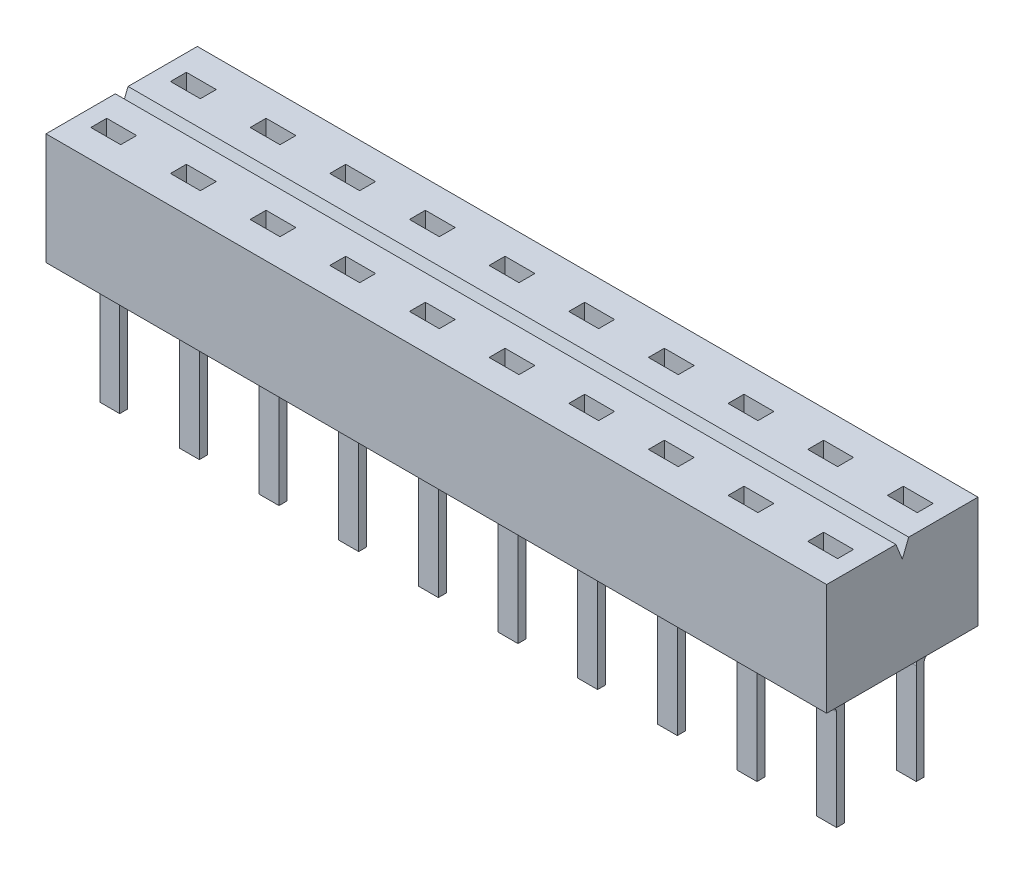
from build123d import *

# Parameters (mm, degrees)
SKETCH1_W            = 24.892
SKETCH1_H            = 4.826
BOSS_EXTRUDE1_DEPTH  = 3.556
BOSS_EXTRUDE2_DEPTH  = 0.635
BOSS_EXTRUDE3_DEPTH  = 0.635
BOSS_EXTRUDE4_DEPTH  = 0.635
BOSS_EXTRUDE5_DEPTH  = 0.635
BOSS_EXTRUDE6_DEPTH  = 0.635
BOSS_EXTRUDE7_DEPTH  = 0.635
BOSS_EXTRUDE8_DEPTH  = 0.635
BOSS_EXTRUDE9_DEPTH  = 0.635
BOSS_EXTRUDE10_DEPTH = 0.635
BOSS_EXTRUDE11_DEPTH = 0.635
BOSS_EXTRUDE12_DEPTH = 0.635
BOSS_EXTRUDE13_DEPTH = 0.635
BOSS_EXTRUDE14_DEPTH = 0.635
BOSS_EXTRUDE15_DEPTH = 0.635
BOSS_EXTRUDE16_DEPTH = 0.635
BOSS_EXTRUDE17_DEPTH = 0.635
BOSS_EXTRUDE18_DEPTH = 0.635
BOSS_EXTRUDE19_DEPTH = 0.635
BOSS_EXTRUDE20_DEPTH = 0.635
BOSS_EXTRUDE21_DEPTH = 0.635
FILLET1_R            = 0.127
FILLET2_R            = 0.381
SKETCH22_W           = 0.9525
SKETCH22_H           = 0.508
CUT_EXTRUDE1_DEPTH   = 3.302
SKETCH23_W           = 0.9525
SKETCH23_H           = 0.508
CUT_EXTRUDE2_DEPTH   = 3.302
SKETCH24_W           = 0.9525
SKETCH24_H           = 0.508
CUT_EXTRUDE3_DEPTH   = 3.302
SKETCH25_W           = 0.9525
SKETCH25_H           = 0.508
CUT_EXTRUDE4_DEPTH   = 3.302
SKETCH26_W           = 0.9525
SKETCH26_H           = 0.508
CUT_EXTRUDE5_DEPTH   = 3.302
SKETCH27_W           = 0.9525
SKETCH27_H           = 0.508
CUT_EXTRUDE6_DEPTH   = 3.302
SKETCH28_W           = 0.9525
SKETCH28_H           = 0.508
CUT_EXTRUDE7_DEPTH   = 3.302
SKETCH29_W           = 0.9525
SKETCH29_H           = 0.508
CUT_EXTRUDE8_DEPTH   = 3.302
SKETCH30_W           = 0.9525
SKETCH30_H           = 0.508
CUT_EXTRUDE9_DEPTH   = 3.302
SKETCH31_W           = 0.9525
SKETCH31_H           = 0.508
CUT_EXTRUDE10_DEPTH  = 3.302
SKETCH32_W           = 0.9525
SKETCH32_H           = 0.508
CUT_EXTRUDE11_DEPTH  = 3.302
SKETCH33_W           = 0.9525
SKETCH33_H           = 0.508
CUT_EXTRUDE12_DEPTH  = 3.302
SKETCH34_W           = 0.9525
SKETCH34_H           = 0.508
CUT_EXTRUDE13_DEPTH  = 3.302
SKETCH35_W           = 0.9525
SKETCH35_H           = 0.508
CUT_EXTRUDE14_DEPTH  = 3.302
SKETCH36_W           = 0.9525
SKETCH36_H           = 0.508
CUT_EXTRUDE15_DEPTH  = 3.302
SKETCH37_W           = 0.9525
SKETCH37_H           = 0.508
CUT_EXTRUDE16_DEPTH  = 3.302
SKETCH38_W           = 0.9525
SKETCH38_H           = 0.508
CUT_EXTRUDE17_DEPTH  = 3.302
SKETCH39_W           = 0.9525
SKETCH39_H           = 0.508
CUT_EXTRUDE18_DEPTH  = 3.302
SKETCH40_W           = 0.9525
SKETCH40_H           = 0.508
CUT_EXTRUDE19_DEPTH  = 3.302
SKETCH41_W           = 0.9525
SKETCH41_H           = 0.508
CUT_EXTRUDE20_DEPTH  = 3.302
CUT_EXTRUDE21_DEPTH  = 25.892


with BuildPart() as part:
    # Sketch1 → Boss-Extrude1 (new body)
    with BuildSketch(Plane.XZ.offset(-0.762)):
        Rectangle(SKETCH1_W, SKETCH1_H)
    extrude(amount=-BOSS_EXTRUDE1_DEPTH)

    # Sketch2 → Boss-Extrude2 (add)
    with BuildSketch(Plane(origin=(8.5725, 0, 0), x_dir=(0, -1, 0), z_dir=(-1, 0, 0))):
        Polygon((0, 1.397), (-0.762, 2.286), (-0.762, 1.895705951), (-0.11682347, 1.143), (3.2512, 1.143), (3.2512, 1.397), align=None)
    extrude(amount=-BOSS_EXTRUDE2_DEPTH)

    # Sketch3 → Boss-Extrude3 (add)
    with BuildSketch(Plane(origin=(6.0325, 0, 0), x_dir=(0, -1, 0), z_dir=(-1, 0, 0))):
        Polygon((0, 1.397), (-0.762, 2.286), (-0.762, 1.895705951), (-0.11682347, 1.143), (3.2512, 1.143), (3.2512, 1.397), align=None)
    extrude(amount=-BOSS_EXTRUDE3_DEPTH)

    # Sketch4 → Boss-Extrude4 (add)
    with BuildSketch(Plane(origin=(3.4925, 0, 0), x_dir=(0, -1, 0), z_dir=(-1, 0, 0))):
        Polygon((0, 1.397), (-0.762, 2.286), (-0.762, 1.895705951), (-0.11682347, 1.143), (3.2512, 1.143), (3.2512, 1.397), align=None)
    extrude(amount=-BOSS_EXTRUDE4_DEPTH)

    # Sketch5 → Boss-Extrude5 (add)
    with BuildSketch(Plane(origin=(0.9525, 0, 0), x_dir=(0, -1, 0), z_dir=(-1, 0, 0))):
        Polygon((0, 1.397), (-0.762, 2.286), (-0.762, 1.895705951), (-0.11682347, 1.143), (3.2512, 1.143), (3.2512, 1.397), align=None)
    extrude(amount=-BOSS_EXTRUDE5_DEPTH)

    # Sketch6 → Boss-Extrude6 (add)
    with BuildSketch(Plane(origin=(-1.5875, 0, 0), x_dir=(0, -1, 0), z_dir=(-1, 0, 0))):
        Polygon((0, 1.397), (-0.762, 2.286), (-0.762, 1.895705951), (-0.11682347, 1.143), (3.2512, 1.143), (3.2512, 1.397), align=None)
    extrude(amount=-BOSS_EXTRUDE6_DEPTH)

    # Sketch7 → Boss-Extrude7 (add)
    with BuildSketch(Plane(origin=(-4.1275, 0, 0), x_dir=(0, -1, 0), z_dir=(-1, 0, 0))):
        Polygon((0, 1.397), (-0.762, 2.286), (-0.762, 1.895705951), (-0.11682347, 1.143), (3.2512, 1.143), (3.2512, 1.397), align=None)
    extrude(amount=-BOSS_EXTRUDE7_DEPTH)

    # Sketch8 → Boss-Extrude8 (add)
    with BuildSketch(Plane(origin=(-6.6675, 0, 0), x_dir=(0, -1, 0), z_dir=(-1, 0, 0))):
        Polygon((0, 1.397), (-0.762, 2.286), (-0.762, 1.895705951), (-0.11682347, 1.143), (3.2512, 1.143), (3.2512, 1.397), align=None)
    extrude(amount=-BOSS_EXTRUDE8_DEPTH)

    # Sketch9 → Boss-Extrude9 (add)
    with BuildSketch(Plane(origin=(-9.2075, 0, 0), x_dir=(0, -1, 0), z_dir=(-1, 0, 0))):
        Polygon((0, 1.397), (-0.762, 2.286), (-0.762, 1.895705951), (-0.11682347, 1.143), (3.2512, 1.143), (3.2512, 1.397), align=None)
    extrude(amount=-BOSS_EXTRUDE9_DEPTH)

    # Sketch10 → Boss-Extrude10 (add)
    with BuildSketch(Plane(origin=(-11.7475, 0, 0), x_dir=(0, -1, 0), z_dir=(-1, 0, 0))):
        Polygon((0, 1.397), (-0.762, 2.286), (-0.762, 1.895705951), (-0.11682347, 1.143), (3.2512, 1.143), (3.2512, 1.397), align=None)
    extrude(amount=-BOSS_EXTRUDE10_DEPTH)

    # Sketch11 → Boss-Extrude11 (add)
    with BuildSketch(Plane(origin=(11.1125, 0, 0), x_dir=(0, -1, 0), z_dir=(-1, 0, 0))):
        Polygon((-0.11682347, -1.143), (-0.762, -1.895705951), (-0.762, -2.286), (0, -1.397), (3.2512, -1.397), (3.2512, -1.143), align=None)
    extrude(amount=-BOSS_EXTRUDE11_DEPTH)

    # Sketch12 → Boss-Extrude12 (add)
    with BuildSketch(Plane(origin=(8.5725, 0, 0), x_dir=(0, -1, 0), z_dir=(-1, 0, 0))):
        Polygon((-0.11682347, -1.143), (-0.762, -1.895705951), (-0.762, -2.286), (0, -1.397), (3.2512, -1.397), (3.2512, -1.143), align=None)
    extrude(amount=-BOSS_EXTRUDE12_DEPTH)

    # Sketch13 → Boss-Extrude13 (add)
    with BuildSketch(Plane(origin=(6.0325, 0, 0), x_dir=(0, -1, 0), z_dir=(-1, 0, 0))):
        Polygon((-0.11682347, -1.143), (-0.762, -1.895705951), (-0.762, -2.286), (0, -1.397), (3.2512, -1.397), (3.2512, -1.143), align=None)
    extrude(amount=-BOSS_EXTRUDE13_DEPTH)

    # Sketch14 → Boss-Extrude14 (add)
    with BuildSketch(Plane(origin=(3.4925, 0, 0), x_dir=(0, -1, 0), z_dir=(-1, 0, 0))):
        Polygon((-0.11682347, -1.143), (-0.762, -1.895705951), (-0.762, -2.286), (0, -1.397), (3.2512, -1.397), (3.2512, -1.143), align=None)
    extrude(amount=-BOSS_EXTRUDE14_DEPTH)

    # Sketch15 → Boss-Extrude15 (add)
    with BuildSketch(Plane(origin=(0.9525, 0, 0), x_dir=(0, -1, 0), z_dir=(-1, 0, 0))):
        Polygon((-0.11682347, -1.143), (-0.762, -1.895705951), (-0.762, -2.286), (0, -1.397), (3.2512, -1.397), (3.2512, -1.143), align=None)
    extrude(amount=-BOSS_EXTRUDE15_DEPTH)

    # Sketch16 → Boss-Extrude16 (add)
    with BuildSketch(Plane(origin=(-1.5875, 0, 0), x_dir=(0, -1, 0), z_dir=(-1, 0, 0))):
        Polygon((-0.11682347, -1.143), (-0.762, -1.895705951), (-0.762, -2.286), (0, -1.397), (3.2512, -1.397), (3.2512, -1.143), align=None)
    extrude(amount=-BOSS_EXTRUDE16_DEPTH)

    # Sketch17 → Boss-Extrude17 (add)
    with BuildSketch(Plane(origin=(-4.1275, 0, 0), x_dir=(0, -1, 0), z_dir=(-1, 0, 0))):
        Polygon((-0.11682347, -1.143), (-0.762, -1.895705951), (-0.762, -2.286), (0, -1.397), (3.2512, -1.397), (3.2512, -1.143), align=None)
    extrude(amount=-BOSS_EXTRUDE17_DEPTH)

    # Sketch18 → Boss-Extrude18 (add)
    with BuildSketch(Plane(origin=(-6.6675, 0, 0), x_dir=(0, -1, 0), z_dir=(-1, 0, 0))):
        Polygon((-0.11682347, -1.143), (-0.762, -1.895705951), (-0.762, -2.286), (0, -1.397), (3.2512, -1.397), (3.2512, -1.143), align=None)
    extrude(amount=-BOSS_EXTRUDE18_DEPTH)

    # Sketch19 → Boss-Extrude19 (add)
    with BuildSketch(Plane(origin=(-9.2075, 0, 0), x_dir=(0, -1, 0), z_dir=(-1, 0, 0))):
        Polygon((-0.11682347, -1.143), (-0.762, -1.895705951), (-0.762, -2.286), (0, -1.397), (3.2512, -1.397), (3.2512, -1.143), align=None)
    extrude(amount=-BOSS_EXTRUDE19_DEPTH)

    # Sketch20 → Boss-Extrude20 (add)
    with BuildSketch(Plane(origin=(-11.7475, 0, 0), x_dir=(0, -1, 0), z_dir=(-1, 0, 0))):
        Polygon((-0.11682347, -1.143), (-0.762, -1.895705951), (-0.762, -2.286), (0, -1.397), (3.2512, -1.397), (3.2512, -1.143), align=None)
    extrude(amount=-BOSS_EXTRUDE20_DEPTH)

    # Sketch21 → Boss-Extrude21 (add)
    with BuildSketch(Plane(origin=(11.1125, 0, 0), x_dir=(0, -1, 0), z_dir=(-1, 0, 0))):
        Polygon((0, 1.397), (-0.762, 2.286), (-0.762, 1.895705951), (-0.11682347, 1.143), (3.2512, 1.143), (3.2512, 1.397), align=None)
    extrude(amount=-BOSS_EXTRUDE21_DEPTH)

    # Fillet1
    fillet1_edges = [part.edges().sort_by_distance(p)[0] for p in [
        (-6.35, 0, 1.397),
        (-8.89, 0, 1.397),
        (-11.43, 0, 1.397),
        (8.89, 0, 1.397),
        (11.43, 0, -1.397),
        (8.89, 0, -1.397),
        (6.35, 0, -1.397),
        (3.81, 0, -1.397),
        (1.27, 0, -1.397),
        (-1.27, 0, -1.397),
        (-3.81, 0, -1.397),
        (-6.35, 0, -1.397),
        (-8.89, 0, -1.397),
        (-11.43, 0, -1.397),
        (6.35, 0, 1.397),
        (11.43, 0, 1.397),
        (3.81, 0, 1.397),
        (1.27, 0, 1.397),
        (-1.27, 0, 1.397),
        (-3.81, 0, 1.397),
    ]]
    fillet(fillet1_edges, radius=FILLET1_R)

    # Fillet2
    fillet2_edges = [part.edges().sort_by_distance(p)[0] for p in [
        (-6.35, 0.11682347, 1.143),
        (-8.89, 0.11682347, 1.143),
        (-11.43, 0.11682347, 1.143),
        (11.43, 0.11682347, -1.143),
        (8.89, 0.11682347, 1.143),
        (8.89, 0.11682347, -1.143),
        (6.35, 0.11682347, -1.143),
        (3.81, 0.11682347, -1.143),
        (1.27, 0.11682347, -1.143),
        (-1.27, 0.11682347, -1.143),
        (-3.81, 0.11682347, -1.143),
        (-6.35, 0.11682347, -1.143),
        (-8.89, 0.11682347, -1.143),
        (-11.43, 0.11682347, -1.143),
        (11.43, 0.11682347, 1.143),
        (6.35, 0.11682347, 1.143),
        (3.81, 0.11682347, 1.143),
        (1.27, 0.11682347, 1.143),
        (-1.27, 0.11682347, 1.143),
        (-3.81, 0.11682347, 1.143),
    ]]
    fillet(fillet2_edges, radius=FILLET2_R)

    # Sketch22 → Cut-Extrude1 (cut)
    with BuildSketch(Plane(origin=(0, 4.318, 0), x_dir=(-1, 0, 0), z_dir=(0, 1, 0))):
        with Locations((11.43, 1.27)):
            Rectangle(SKETCH22_W, SKETCH22_H)
    extrude(amount=-CUT_EXTRUDE1_DEPTH, mode=Mode.SUBTRACT)

    # Sketch23 → Cut-Extrude2 (cut)
    with BuildSketch(Plane(origin=(0, 4.318, 0), x_dir=(-1, 0, 0), z_dir=(0, 1, 0))):
        with Locations((8.89, 1.27)):
            Rectangle(SKETCH23_W, SKETCH23_H)
    extrude(amount=-CUT_EXTRUDE2_DEPTH, mode=Mode.SUBTRACT)

    # Sketch24 → Cut-Extrude3 (cut)
    with BuildSketch(Plane(origin=(0, 4.318, 0), x_dir=(-1, 0, 0), z_dir=(0, 1, 0))):
        with Locations((-8.89, 1.27)):
            Rectangle(SKETCH24_W, SKETCH24_H)
    extrude(amount=-CUT_EXTRUDE3_DEPTH, mode=Mode.SUBTRACT)

    # Sketch25 → Cut-Extrude4 (cut)
    with BuildSketch(Plane(origin=(0, 4.318, 0), x_dir=(-1, 0, 0), z_dir=(0, 1, 0))):
        with Locations((-6.35, 1.27)):
            Rectangle(SKETCH25_W, SKETCH25_H)
    extrude(amount=-CUT_EXTRUDE4_DEPTH, mode=Mode.SUBTRACT)

    # Sketch26 → Cut-Extrude5 (cut)
    with BuildSketch(Plane(origin=(0, 4.318, 0), x_dir=(-1, 0, 0), z_dir=(0, 1, 0))):
        with Locations((-3.81, 1.27)):
            Rectangle(SKETCH26_W, SKETCH26_H)
    extrude(amount=-CUT_EXTRUDE5_DEPTH, mode=Mode.SUBTRACT)

    # Sketch27 → Cut-Extrude6 (cut)
    with BuildSketch(Plane(origin=(0, 4.318, 0), x_dir=(-1, 0, 0), z_dir=(0, 1, 0))):
        with Locations((-1.27, 1.27)):
            Rectangle(SKETCH27_W, SKETCH27_H)
    extrude(amount=-CUT_EXTRUDE6_DEPTH, mode=Mode.SUBTRACT)

    # Sketch28 → Cut-Extrude7 (cut)
    with BuildSketch(Plane(origin=(0, 4.318, 0), x_dir=(-1, 0, 0), z_dir=(0, 1, 0))):
        with Locations((1.27, 1.27)):
            Rectangle(SKETCH28_W, SKETCH28_H)
    extrude(amount=-CUT_EXTRUDE7_DEPTH, mode=Mode.SUBTRACT)

    # Sketch29 → Cut-Extrude8 (cut)
    with BuildSketch(Plane(origin=(0, 4.318, 0), x_dir=(-1, 0, 0), z_dir=(0, 1, 0))):
        with Locations((3.81, 1.27)):
            Rectangle(SKETCH29_W, SKETCH29_H)
    extrude(amount=-CUT_EXTRUDE8_DEPTH, mode=Mode.SUBTRACT)

    # Sketch30 → Cut-Extrude9 (cut)
    with BuildSketch(Plane(origin=(0, 4.318, 0), x_dir=(-1, 0, 0), z_dir=(0, 1, 0))):
        with Locations((6.35, 1.27)):
            Rectangle(SKETCH30_W, SKETCH30_H)
    extrude(amount=-CUT_EXTRUDE9_DEPTH, mode=Mode.SUBTRACT)

    # Sketch31 → Cut-Extrude10 (cut)
    with BuildSketch(Plane(origin=(0, 4.318, 0), x_dir=(-1, 0, 0), z_dir=(0, 1, 0))):
        with Locations((-11.43, -1.27)):
            Rectangle(SKETCH31_W, SKETCH31_H)
    extrude(amount=-CUT_EXTRUDE10_DEPTH, mode=Mode.SUBTRACT)

    # Sketch32 → Cut-Extrude11 (cut)
    with BuildSketch(Plane(origin=(0, 4.318, 0), x_dir=(-1, 0, 0), z_dir=(0, 1, 0))):
        with Locations((-8.89, -1.27)):
            Rectangle(SKETCH32_W, SKETCH32_H)
    extrude(amount=-CUT_EXTRUDE11_DEPTH, mode=Mode.SUBTRACT)

    # Sketch33 → Cut-Extrude12 (cut)
    with BuildSketch(Plane(origin=(0, 4.318, 0), x_dir=(-1, 0, 0), z_dir=(0, 1, 0))):
        with Locations((-6.35, -1.27)):
            Rectangle(SKETCH33_W, SKETCH33_H)
    extrude(amount=-CUT_EXTRUDE12_DEPTH, mode=Mode.SUBTRACT)

    # Sketch34 → Cut-Extrude13 (cut)
    with BuildSketch(Plane(origin=(0, 4.318, 0), x_dir=(-1, 0, 0), z_dir=(0, 1, 0))):
        with Locations((-3.81, -1.27)):
            Rectangle(SKETCH34_W, SKETCH34_H)
    extrude(amount=-CUT_EXTRUDE13_DEPTH, mode=Mode.SUBTRACT)

    # Sketch35 → Cut-Extrude14 (cut)
    with BuildSketch(Plane(origin=(0, 4.318, 0), x_dir=(-1, 0, 0), z_dir=(0, 1, 0))):
        with Locations((-1.27, -1.27)):
            Rectangle(SKETCH35_W, SKETCH35_H)
    extrude(amount=-CUT_EXTRUDE14_DEPTH, mode=Mode.SUBTRACT)

    # Sketch36 → Cut-Extrude15 (cut)
    with BuildSketch(Plane(origin=(0, 4.318, 0), x_dir=(-1, 0, 0), z_dir=(0, 1, 0))):
        with Locations((1.27, -1.27)):
            Rectangle(SKETCH36_W, SKETCH36_H)
    extrude(amount=-CUT_EXTRUDE15_DEPTH, mode=Mode.SUBTRACT)

    # Sketch37 → Cut-Extrude16 (cut)
    with BuildSketch(Plane(origin=(0, 4.318, 0), x_dir=(-1, 0, 0), z_dir=(0, 1, 0))):
        with Locations((3.81, -1.27)):
            Rectangle(SKETCH37_W, SKETCH37_H)
    extrude(amount=-CUT_EXTRUDE16_DEPTH, mode=Mode.SUBTRACT)

    # Sketch38 → Cut-Extrude17 (cut)
    with BuildSketch(Plane(origin=(0, 4.318, 0), x_dir=(-1, 0, 0), z_dir=(0, 1, 0))):
        with Locations((6.35, -1.27)):
            Rectangle(SKETCH38_W, SKETCH38_H)
    extrude(amount=-CUT_EXTRUDE17_DEPTH, mode=Mode.SUBTRACT)

    # Sketch39 → Cut-Extrude18 (cut)
    with BuildSketch(Plane(origin=(0, 4.318, 0), x_dir=(-1, 0, 0), z_dir=(0, 1, 0))):
        with Locations((8.89, -1.27)):
            Rectangle(SKETCH39_W, SKETCH39_H)
    extrude(amount=-CUT_EXTRUDE18_DEPTH, mode=Mode.SUBTRACT)

    # Sketch40 → Cut-Extrude19 (cut)
    with BuildSketch(Plane(origin=(0, 4.318, 0), x_dir=(-1, 0, 0), z_dir=(0, 1, 0))):
        with Locations((11.43, -1.27)):
            Rectangle(SKETCH40_W, SKETCH40_H)
    extrude(amount=-CUT_EXTRUDE19_DEPTH, mode=Mode.SUBTRACT)

    # Sketch41 → Cut-Extrude20 (cut)
    with BuildSketch(Plane(origin=(0, 4.318, 0), x_dir=(-1, 0, 0), z_dir=(0, 1, 0))):
        with Locations((-11.43, 1.27)):
            Rectangle(SKETCH41_W, SKETCH41_H)
    extrude(amount=-CUT_EXTRUDE20_DEPTH, mode=Mode.SUBTRACT)

    # Sketch42 → Cut-Extrude21 (cut, through all)
    with BuildSketch(Plane.ZY.offset(12.446)):
        Polygon((-0.2032, 4.318), (0, 3.81), (0.2032, 4.318), align=None)
    extrude(amount=-CUT_EXTRUDE21_DEPTH, mode=Mode.SUBTRACT)


solid = part.part
